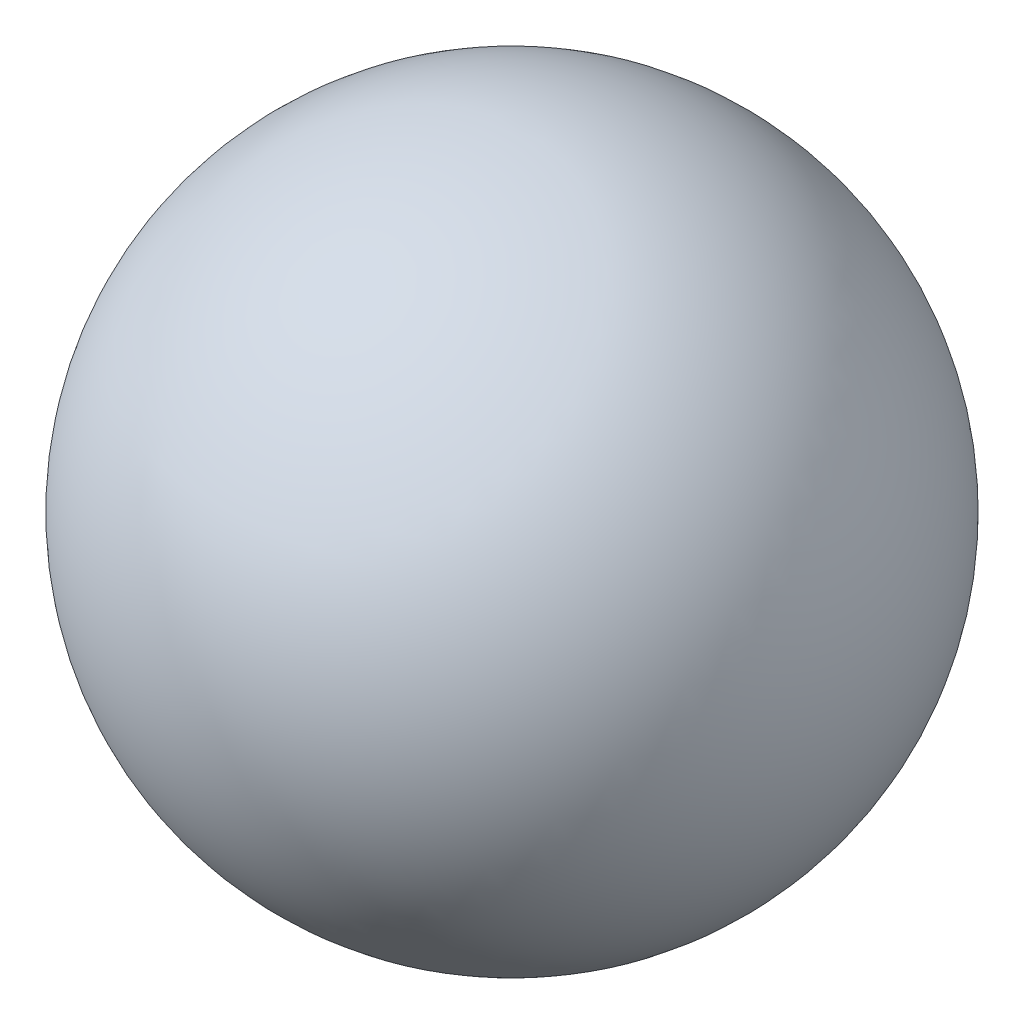
from build123d import *


with BuildPart() as part:
    # Sketch1 → Revolve4 (revolve)
    with BuildSketch(Plane.XY):
        with BuildLine():
            Line((0, -9.525), (0, 9.525))
            ThreePointArc((0, 9.525), (9.525, 0), (0, -9.525))
        make_face()
    revolve(axis=Axis((0, -9.525, 0), (0, 1, 0)))


solid = part.part
